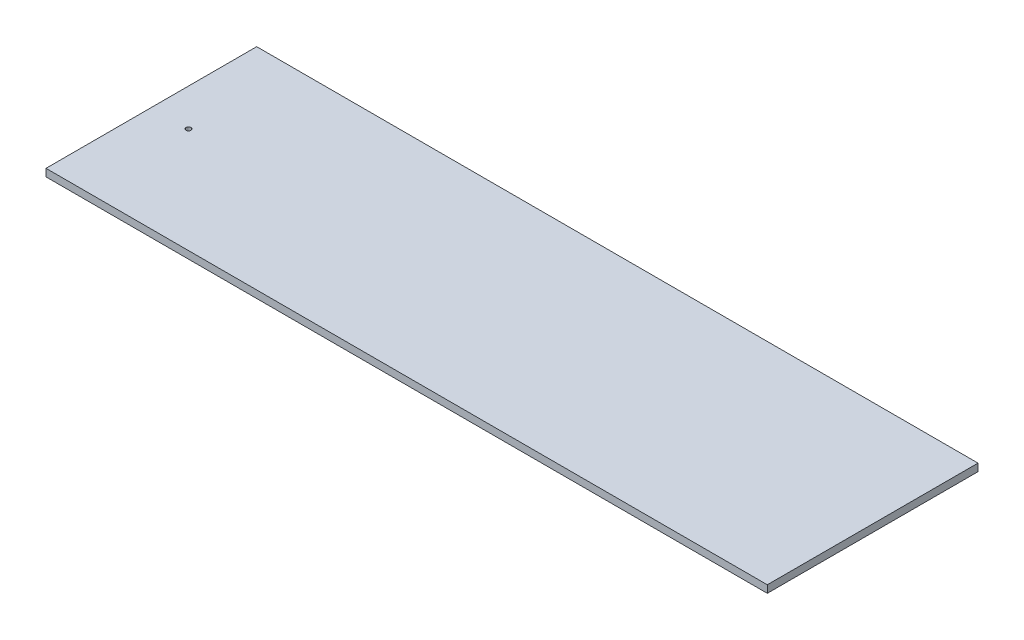
from build123d import *

# Parameters (mm, degrees)
SKETCH1_W           = 291
SKETCH1_H           = 85
SKETCH1_R           = 1
BOSS_EXTRUDE1_DEPTH = 3


with BuildPart() as part:
    # Sketch1 → Boss-Extrude1 (new body)
    with BuildSketch(Plane(origin=(0, 3, 0), x_dir=(1, 0, 0), z_dir=(0, 1, 0))):
        Rectangle(SKETCH1_W, SKETCH1_H)
        with Locations((-130.5, 0)):
            Circle(SKETCH1_R, mode=Mode.SUBTRACT)
    extrude(amount=-BOSS_EXTRUDE1_DEPTH)


solid = part.part
